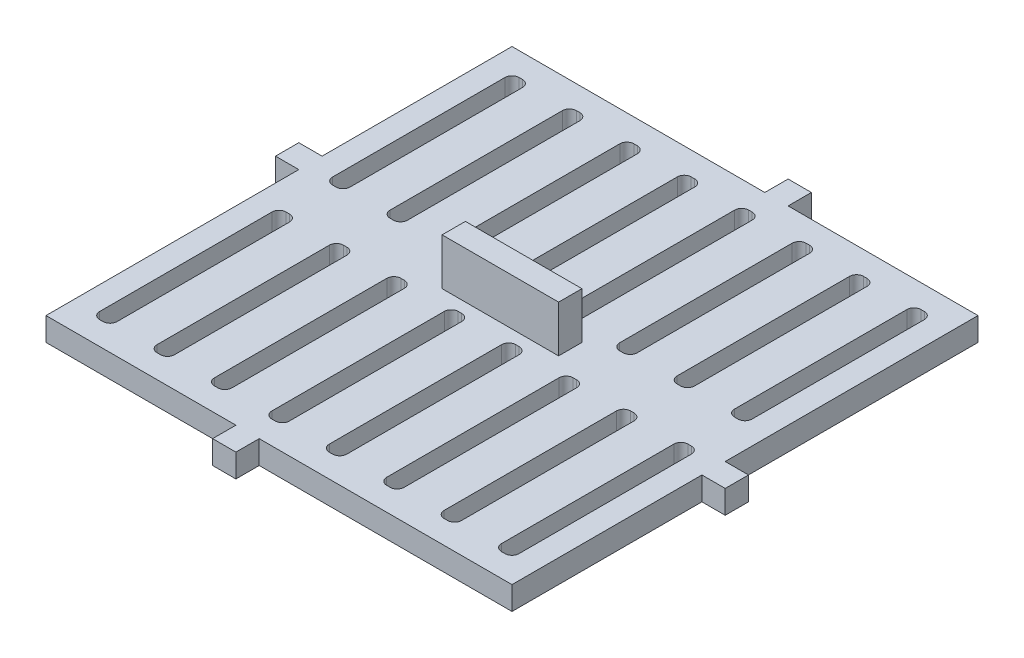
from build123d import *

# Parameters (mm, degrees)
SKETCH2_W           = 50.8
SKETCH2_H           = 50.8
BOSS_EXTRUDE1_DEPTH = 2.54
CUT_EXTRUDE1_DEPTH  = 2.54
SKETCH6_W           = 2.54
SKETCH6_H           = 2.54
BOSS_EXTRUDE2_DEPTH = 2.54
SKETCH7_W           = 2.54
SKETCH7_H           = 2.54
BOSS_EXTRUDE3_DEPTH = 2.54
SKETCH8_W           = 2.54
SKETCH8_H           = 2.54
BOSS_EXTRUDE4_DEPTH = 2.54
SKETCH9_W           = 2.54
SKETCH9_H           = 2.54
BOSS_EXTRUDE5_DEPTH = 2.54
SKETCH10_W          = 12.7
SKETCH10_H          = 2.54
BOSS_EXTRUDE6_DEPTH = 5.08


with BuildPart() as part:
    # Sketch2 → Boss-Extrude1 (new body)
    with BuildSketch(Plane(origin=(0, 0, 0), x_dir=(1, 0, 0), z_dir=(0, 1, 0))):
        with Locations((25.4, -25.4)):
            Rectangle(SKETCH2_W, SKETCH2_H)
    extrude(amount=BOSS_EXTRUDE1_DEPTH)

    # Sketch3 → Cut-Extrude1 (cut)
    with BuildSketch(Plane(origin=(0, 2.54, 0), x_dir=(1, 0, 0), z_dir=(0, 1, 0))):
        with BuildLine():
            Line((8.799285714, -3.302), (8.799285714, -22.098))
            ThreePointArc((8.799285714, -22.098), (9.022470347, -22.636815367), (9.561285714, -22.86))
            Line((9.561285714, -22.86), (9.942285714, -22.86))
            ThreePointArc((9.942285714, -22.86), (10.481101082, -22.636815367), (10.704285714, -22.098))
            Line((10.704285714, -22.098), (10.704285714, -3.302))
            ThreePointArc((10.704285714, -3.302), (10.481101082, -2.763184633), (9.942285714, -2.54))
            Line((9.942285714, -2.54), (9.561285714, -2.54))
            ThreePointArc((9.561285714, -2.54), (9.022470347, -2.763184633), (8.799285714, -3.302))
        make_face()
        with BuildLine():
            Line((3.302, -2.54), (3.683, -2.54))
            ThreePointArc((3.683, -2.54), (4.221815367, -2.763184633), (4.445, -3.302))
            Line((4.445, -3.302), (4.445, -22.098))
            ThreePointArc((4.445, -22.098), (4.221815367, -22.636815367), (3.683, -22.86))
            Line((3.683, -22.86), (3.302, -22.86))
            ThreePointArc((3.302, -22.86), (2.763184633, -22.636815367), (2.54, -22.098))
            Line((2.54, -22.098), (2.54, -3.302))
            ThreePointArc((2.54, -3.302), (2.763184633, -2.763184633), (3.302, -2.54))
        make_face()
        with BuildLine():
            Line((15.058571429, -3.302), (15.058571429, -22.098))
            ThreePointArc((15.058571429, -22.098), (15.281756061, -22.636815367), (15.820571429, -22.86))
            Line((15.820571429, -22.86), (16.201571429, -22.86))
            ThreePointArc((16.201571429, -22.86), (16.740386796, -22.636815367), (16.963571429, -22.098))
            Line((16.963571429, -22.098), (16.963571429, -3.302))
            ThreePointArc((16.963571429, -3.302), (16.740386796, -2.763184633), (16.201571429, -2.54))
            Line((16.201571429, -2.54), (15.820571429, -2.54))
            ThreePointArc((15.820571429, -2.54), (15.281756061, -2.763184633), (15.058571429, -3.302))
        make_face()
        with BuildLine():
            Line((21.317857143, -3.302), (21.317857143, -22.098))
            ThreePointArc((21.317857143, -22.098), (21.541041776, -22.636815367), (22.079857143, -22.86))
            Line((22.079857143, -22.86), (22.460857143, -22.86))
            ThreePointArc((22.460857143, -22.86), (22.99967251, -22.636815367), (23.222857143, -22.098))
            Line((23.222857143, -22.098), (23.222857143, -3.302))
            ThreePointArc((23.222857143, -3.302), (22.99967251, -2.763184633), (22.460857143, -2.54))
            Line((22.460857143, -2.54), (22.079857143, -2.54))
            ThreePointArc((22.079857143, -2.54), (21.541041776, -2.763184633), (21.317857143, -3.302))
        make_face()
        with BuildLine():
            Line((27.577142857, -3.302), (27.577142857, -22.098))
            ThreePointArc((27.577142857, -22.098), (27.80032749, -22.636815367), (28.339142857, -22.86))
            Line((28.339142857, -22.86), (28.720142857, -22.86))
            ThreePointArc((28.720142857, -22.86), (29.258958224, -22.636815367), (29.482142857, -22.098))
            Line((29.482142857, -22.098), (29.482142857, -3.302))
            ThreePointArc((29.482142857, -3.302), (29.258958224, -2.763184633), (28.720142857, -2.54))
            Line((28.720142857, -2.54), (28.339142857, -2.54))
            ThreePointArc((28.339142857, -2.54), (27.80032749, -2.763184633), (27.577142857, -3.302))
        make_face()
        with BuildLine():
            Line((33.836428571, -3.302), (33.836428571, -22.098))
            ThreePointArc((33.836428571, -22.098), (34.059613204, -22.636815367), (34.598428571, -22.86))
            Line((34.598428571, -22.86), (34.979428571, -22.86))
            ThreePointArc((34.979428571, -22.86), (35.518243939, -22.636815367), (35.741428571, -22.098))
            Line((35.741428571, -22.098), (35.741428571, -3.302))
            ThreePointArc((35.741428571, -3.302), (35.518243939, -2.763184633), (34.979428571, -2.54))
            Line((34.979428571, -2.54), (34.598428571, -2.54))
            ThreePointArc((34.598428571, -2.54), (34.059613204, -2.763184633), (33.836428571, -3.302))
        make_face()
        with BuildLine():
            Line((40.095714286, -3.302), (40.095714286, -22.098))
            ThreePointArc((40.095714286, -22.098), (40.318898918, -22.636815367), (40.857714286, -22.86))
            Line((40.857714286, -22.86), (41.238714286, -22.86))
            ThreePointArc((41.238714286, -22.86), (41.777529653, -22.636815367), (42.000714286, -22.098))
            Line((42.000714286, -22.098), (42.000714286, -3.302))
            ThreePointArc((42.000714286, -3.302), (41.777529653, -2.763184633), (41.238714286, -2.54))
            Line((41.238714286, -2.54), (40.857714286, -2.54))
            ThreePointArc((40.857714286, -2.54), (40.318898918, -2.763184633), (40.095714286, -3.302))
        make_face()
        with BuildLine():
            Line((46.355, -3.302), (46.355, -22.098))
            ThreePointArc((46.355, -22.098), (46.578184633, -22.636815367), (47.117, -22.86))
            Line((47.117, -22.86), (47.498, -22.86))
            ThreePointArc((47.498, -22.86), (48.036815367, -22.636815367), (48.26, -22.098))
            Line((48.26, -22.098), (48.26, -3.302))
            ThreePointArc((48.26, -3.302), (48.036815367, -2.763184633), (47.498, -2.54))
            Line((47.498, -2.54), (47.117, -2.54))
            ThreePointArc((47.117, -2.54), (46.578184633, -2.763184633), (46.355, -3.302))
        make_face()
        with BuildLine():
            Line((2.54, -28.702), (2.54, -47.498))
            ThreePointArc((2.54, -47.498), (2.763184633, -48.036815367), (3.302, -48.26))
            Line((3.302, -48.26), (3.683, -48.26))
            ThreePointArc((3.683, -48.26), (4.221815367, -48.036815367), (4.445, -47.498))
            Line((4.445, -47.498), (4.445, -28.702))
            ThreePointArc((4.445, -28.702), (4.221815367, -28.163184633), (3.683, -27.94))
            Line((3.683, -27.94), (3.302, -27.94))
            ThreePointArc((3.302, -27.94), (2.763184633, -28.163184633), (2.54, -28.702))
        make_face()
        with BuildLine():
            Line((8.799285714, -28.702), (8.799285714, -47.498))
            ThreePointArc((8.799285714, -47.498), (9.022470347, -48.036815367), (9.561285714, -48.26))
            Line((9.561285714, -48.26), (9.942285714, -48.26))
            ThreePointArc((9.942285714, -48.26), (10.481101082, -48.036815367), (10.704285714, -47.498))
            Line((10.704285714, -47.498), (10.704285714, -28.702))
            ThreePointArc((10.704285714, -28.702), (10.481101082, -28.163184633), (9.942285714, -27.94))
            Line((9.942285714, -27.94), (9.561285714, -27.94))
            ThreePointArc((9.561285714, -27.94), (9.022470347, -28.163184633), (8.799285714, -28.702))
        make_face()
        with BuildLine():
            Line((15.058571429, -28.702), (15.058571429, -47.498))
            ThreePointArc((15.058571429, -47.498), (15.281756061, -48.036815367), (15.820571429, -48.26))
            Line((15.820571429, -48.26), (16.201571429, -48.26))
            ThreePointArc((16.201571429, -48.26), (16.740386796, -48.036815367), (16.963571429, -47.498))
            Line((16.963571429, -47.498), (16.963571429, -28.702))
            ThreePointArc((16.963571429, -28.702), (16.740386796, -28.163184633), (16.201571429, -27.94))
            Line((16.201571429, -27.94), (15.820571429, -27.94))
            ThreePointArc((15.820571429, -27.94), (15.281756061, -28.163184633), (15.058571429, -28.702))
        make_face()
        with BuildLine():
            Line((21.317857143, -28.702), (21.317857143, -47.498))
            ThreePointArc((21.317857143, -47.498), (21.541041776, -48.036815367), (22.079857143, -48.26))
            Line((22.079857143, -48.26), (22.460857143, -48.26))
            ThreePointArc((22.460857143, -48.26), (22.99967251, -48.036815367), (23.222857143, -47.498))
            Line((23.222857143, -47.498), (23.222857143, -28.702))
            ThreePointArc((23.222857143, -28.702), (22.99967251, -28.163184633), (22.460857143, -27.94))
            Line((22.460857143, -27.94), (22.079857143, -27.94))
            ThreePointArc((22.079857143, -27.94), (21.541041776, -28.163184633), (21.317857143, -28.702))
        make_face()
        with BuildLine():
            Line((27.577142857, -28.702), (27.577142857, -47.498))
            ThreePointArc((27.577142857, -47.498), (27.80032749, -48.036815367), (28.339142857, -48.26))
            Line((28.339142857, -48.26), (28.720142857, -48.26))
            ThreePointArc((28.720142857, -48.26), (29.258958224, -48.036815367), (29.482142857, -47.498))
            Line((29.482142857, -47.498), (29.482142857, -28.702))
            ThreePointArc((29.482142857, -28.702), (29.258958224, -28.163184633), (28.720142857, -27.94))
            Line((28.720142857, -27.94), (28.339142857, -27.94))
            ThreePointArc((28.339142857, -27.94), (27.80032749, -28.163184633), (27.577142857, -28.702))
        make_face()
        with BuildLine():
            Line((33.836428571, -28.702), (33.836428571, -47.498))
            ThreePointArc((33.836428571, -47.498), (34.059613204, -48.036815367), (34.598428571, -48.26))
            Line((34.598428571, -48.26), (34.979428571, -48.26))
            ThreePointArc((34.979428571, -48.26), (35.518243939, -48.036815367), (35.741428571, -47.498))
            Line((35.741428571, -47.498), (35.741428571, -28.702))
            ThreePointArc((35.741428571, -28.702), (35.518243939, -28.163184633), (34.979428571, -27.94))
            Line((34.979428571, -27.94), (34.598428571, -27.94))
            ThreePointArc((34.598428571, -27.94), (34.059613204, -28.163184633), (33.836428571, -28.702))
        make_face()
        with BuildLine():
            Line((40.095714286, -28.702), (40.095714286, -47.498))
            ThreePointArc((40.095714286, -47.498), (40.318898918, -48.036815367), (40.857714286, -48.26))
            Line((40.857714286, -48.26), (41.238714286, -48.26))
            ThreePointArc((41.238714286, -48.26), (41.777529653, -48.036815367), (42.000714286, -47.498))
            Line((42.000714286, -47.498), (42.000714286, -28.702))
            ThreePointArc((42.000714286, -28.702), (41.777529653, -28.163184633), (41.238714286, -27.94))
            Line((41.238714286, -27.94), (40.857714286, -27.94))
            ThreePointArc((40.857714286, -27.94), (40.318898918, -28.163184633), (40.095714286, -28.702))
        make_face()
        with BuildLine():
            Line((46.355, -28.702), (46.355, -47.498))
            ThreePointArc((46.355, -47.498), (46.578184633, -48.036815367), (47.117, -48.26))
            Line((47.117, -48.26), (47.498, -48.26))
            ThreePointArc((47.498, -48.26), (48.036815367, -48.036815367), (48.26, -47.498))
            Line((48.26, -47.498), (48.26, -28.702))
            ThreePointArc((48.26, -28.702), (48.036815367, -28.163184633), (47.498, -27.94))
            Line((47.498, -27.94), (47.117, -27.94))
            ThreePointArc((47.117, -27.94), (46.578184633, -28.163184633), (46.355, -28.702))
        make_face()
    extrude(amount=-CUT_EXTRUDE1_DEPTH, mode=Mode.SUBTRACT)

    # Sketch6 → Boss-Extrude2 (add)
    with BuildSketch(Plane.XY.offset(50.8)):
        with Locations((21.971, 1.27)):
            Rectangle(SKETCH6_W, SKETCH6_H)
    extrude(amount=BOSS_EXTRUDE2_DEPTH)

    # Sketch7 → Boss-Extrude3 (add)
    with BuildSketch(Plane.ZY):
        with Locations((21.971, 1.27)):
            Rectangle(SKETCH7_W, SKETCH7_H)
    extrude(amount=BOSS_EXTRUDE3_DEPTH)

    # Sketch8 → Boss-Extrude4 (add)
    with BuildSketch(Plane(origin=(0, 0, 0), x_dir=(-1, 0, 0), z_dir=(0, 0, -1))):
        with Locations((-28.829, 1.27)):
            Rectangle(SKETCH8_W, SKETCH8_H)
    extrude(amount=BOSS_EXTRUDE4_DEPTH)

    # Sketch9 → Boss-Extrude5 (add)
    with BuildSketch(Plane(origin=(50.8, 0, 0), x_dir=(0, 0, -1), z_dir=(1, 0, 0))):
        with Locations((-28.829, 1.27)):
            Rectangle(SKETCH9_W, SKETCH9_H)
    extrude(amount=BOSS_EXTRUDE5_DEPTH)

    # Sketch10 → Boss-Extrude6 (add)
    with BuildSketch(Plane(origin=(0, 2.54, 0), x_dir=(1, 0, 0), z_dir=(0, 1, 0))):
        with Locations((25.4, -25.4)):
            Rectangle(SKETCH10_W, SKETCH10_H)
    extrude(amount=BOSS_EXTRUDE6_DEPTH)


solid = part.part
